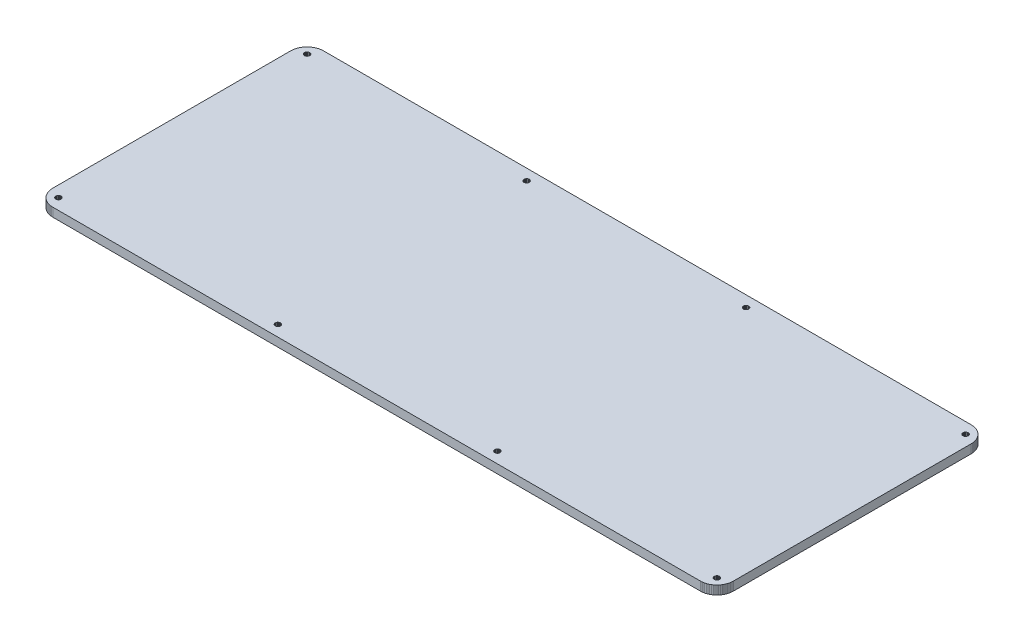
from build123d import *

# Parameters (mm, degrees)
BOSS_EXTRUDE1_DEPTH = 4.7625


with BuildPart() as part:
    # Sketch1 → Boss-Extrude1 (new body)
    with BuildSketch(Plane(origin=(0, 0, 0), x_dir=(1, 0, 0), z_dir=(0, 1, 0))):
        Polygon((362.807, 147.967), (363.513, 147.941), (364.215, 147.857), (364.91, 147.719), (365.591, 147.527), (366.254, 147.282), (366.896, 146.987), (367.51, 146.641), (368.099, 146.25), (368.653, 145.812), (369.171, 145.331), (369.651, 144.812), (370.089, 144.259), (370.48, 143.67), (370.826, 143.053), (371.122, 142.412), (371.369, 141.749), (371.56, 141.07), (371.697, 140.375), (371.778, 139.674), (371.807, 138.967), (371.807, 9.09091), (371.778, 8.38535), (371.697, 7.68396), (371.56, 6.99079), (371.369, 6.31003), (371.122, 5.6472), (370.826, 5.00641), (370.48, 4.38905), (370.089, 3.80062), (369.651, 3.24666), (369.171, 2.72852), (368.653, 2.24758), (368.099, 1.81074), (367.51, 1.418), (366.896, 1.07211), (366.254, 0.777215), (365.591, 0.531922), (364.91, 0.340376), (364.215, 0.202572), (363.513, 0.118511), (362.807, 0.0909507), (9.09507, 0.0909507), (8.3881, 0.118511), (7.68671, 0.202572), (6.99216, 0.340376), (6.31278, 0.531922), (5.64995, 0.777215), (5.00916, 1.07211), (4.3918, 1.418), (3.8034, 1.81074), (3.24942, 2.24758), (2.73127, 2.72852), (2.25034, 3.24666), (1.81212, 3.80062), (1.42076, 4.38905), (1.07487, 5.00641), (0.77997, 5.6472), (0.534681, 6.31003), (0.343131, 6.99079), (0.205328, 7.68396), (0.121267, 8.38535), (0.0937066, 9.09228), (0.0950846, 138.967), (0.121267, 139.674), (0.205328, 140.375), (0.343131, 141.07), (0.534681, 141.749), (0.77997, 142.412), (1.07487, 143.053), (1.42076, 143.67), (1.81212, 144.259), (2.25034, 144.812), (2.73127, 145.331), (3.24942, 145.812), (3.8034, 146.25), (4.3918, 146.641), (5.00916, 146.987), (5.64995, 147.282), (6.31278, 147.527), (6.99216, 147.719), (7.68671, 147.857), (8.3881, 147.941), (9.09507, 147.968), align=None)
        Polygon((365.326, 7.51858), (364.917, 7.31188), (364.589, 6.98253), (364.381, 6.57186), (364.307, 6.11572), (364.381, 5.66099), (364.589, 5.25032), (364.917, 4.92372), (365.326, 4.71428), (365.781, 4.64125), (366.24, 4.71428), (366.649, 4.92372), (366.977, 5.25032), (367.185, 5.66099), (367.259, 6.11572), (367.185, 6.57186), (366.977, 6.98253), (366.649, 7.31188), (366.24, 7.51858), (365.781, 7.5916), align=None, mode=Mode.SUBTRACT)
        Polygon((245.438, 7.51858), (245.027, 7.31188), (244.703, 6.98253), (244.492, 6.57186), (244.42, 6.11572), (244.492, 5.66099), (244.703, 5.25032), (245.027, 4.92372), (245.438, 4.71428), (245.894, 4.64125), (246.35, 4.71428), (246.761, 4.92372), (247.088, 5.25032), (247.297, 5.66099), (247.37, 6.11572), (247.297, 6.57186), (247.088, 6.98253), (246.761, 7.31188), (246.35, 7.51858), (245.894, 7.5916), align=None, mode=Mode.SUBTRACT)
        Polygon((125.552, 7.51858), (125.138, 7.31188), (124.815, 6.98253), (124.604, 6.57186), (124.532, 6.11572), (124.604, 5.66099), (124.815, 5.25032), (125.138, 4.92372), (125.552, 4.71428), (126.007, 4.64125), (126.463, 4.71428), (126.873, 4.92372), (127.201, 5.25032), (127.409, 5.66099), (127.482, 6.11572), (127.409, 6.57186), (127.201, 6.98253), (126.873, 7.31188), (126.463, 7.51858), (126.007, 7.5916), align=None, mode=Mode.SUBTRACT)
        Polygon((5.66374, 7.51858), (5.25307, 7.31188), (4.9251, 6.98253), (4.71703, 6.57186), (4.644, 6.11572), (4.71703, 5.66099), (4.9251, 5.25032), (5.25307, 4.92372), (5.66374, 4.71428), (6.11851, 4.64125), (6.57461, 4.71428), (6.98528, 4.92372), (7.31326, 5.25032), (7.52133, 5.66099), (7.59435, 6.11572), (7.52133, 6.57186), (7.31326, 6.98253), (6.98528, 7.31188), (6.57461, 7.51858), (6.11851, 7.5916), align=None, mode=Mode.SUBTRACT)
        Polygon((125.552, 143.345), (125.138, 143.137), (124.815, 142.809), (124.604, 142.398), (124.532, 141.942), (124.604, 141.487), (124.815, 141.077), (125.138, 140.75), (125.552, 140.541), (126.007, 140.468), (126.463, 140.541), (126.873, 140.75), (127.201, 141.077), (127.409, 141.487), (127.482, 141.942), (127.409, 142.398), (127.201, 142.809), (126.873, 143.137), (126.463, 143.345), (126.007, 143.417), align=None, mode=Mode.SUBTRACT)
        Polygon((245.438, 143.345), (245.027, 143.137), (244.703, 142.809), (244.492, 142.398), (244.42, 141.942), (244.492, 141.487), (244.703, 141.077), (245.027, 140.75), (245.438, 140.541), (245.894, 140.468), (246.35, 140.541), (246.761, 140.75), (247.088, 141.077), (247.297, 141.487), (247.37, 141.942), (247.297, 142.398), (247.088, 142.809), (246.761, 143.137), (246.35, 143.345), (245.894, 143.417), align=None, mode=Mode.SUBTRACT)
        Polygon((365.326, 143.345), (364.917, 143.137), (364.589, 142.809), (364.381, 142.398), (364.307, 141.942), (364.381, 141.487), (364.589, 141.077), (364.917, 140.75), (365.326, 140.541), (365.781, 140.468), (366.24, 140.541), (366.649, 140.75), (366.977, 141.077), (367.185, 141.487), (367.259, 141.942), (367.185, 142.398), (366.977, 142.809), (366.649, 143.137), (366.24, 143.345), (365.781, 143.417), align=None, mode=Mode.SUBTRACT)
        Polygon((5.66374, 143.345), (5.25307, 143.137), (4.9251, 142.809), (4.71703, 142.398), (4.644, 141.942), (4.71703, 141.487), (4.9251, 141.077), (5.25307, 140.75), (5.66374, 140.541), (6.11851, 140.468), (6.57461, 140.541), (6.98528, 140.75), (7.31326, 141.077), (7.52133, 141.487), (7.59435, 141.942), (7.52133, 142.398), (7.31326, 142.809), (6.98528, 143.137), (6.57461, 143.345), (6.11851, 143.417), align=None, mode=Mode.SUBTRACT)
    extrude(amount=BOSS_EXTRUDE1_DEPTH)


solid = part.part
